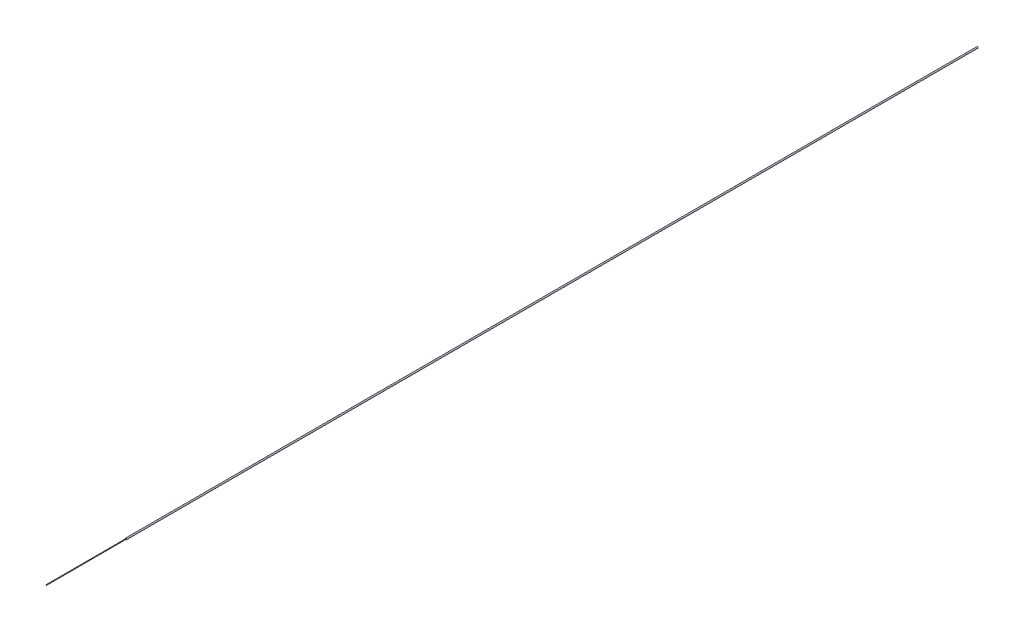
from build123d import *

# Parameters (mm, degrees)
SKETCH1_R           = 1.143
BOSS_EXTRUDE1_DEPTH = 1389
SKETCH4_R           = 0.5


with BuildPart() as part:
    # Sketch1 → Boss-Extrude1 (new body)
    with BuildSketch(Plane.XY):
        Circle(SKETCH1_R)
    extrude(amount=BOSS_EXTRUDE1_DEPTH)

    # Sweep2: sweep along a curve in space
    with BuildLine() as sweep2_path:
        add(Edge.make_bspline(
            [(0, 0, 1389), (0.18176705, 0, 1518.999872926)],
            knots=[0, 0, 1, 1], degree=1))
    # Sketch4 → Sweep2 (sweep)
    with BuildSketch(Plane(origin=(0, 0, 1389), x_dir=(-1, 0, 0), z_dir=(0, 0, -1))):
        Circle(SKETCH4_R)
    sweep(path=sweep2_path.line)


solid = part.part
